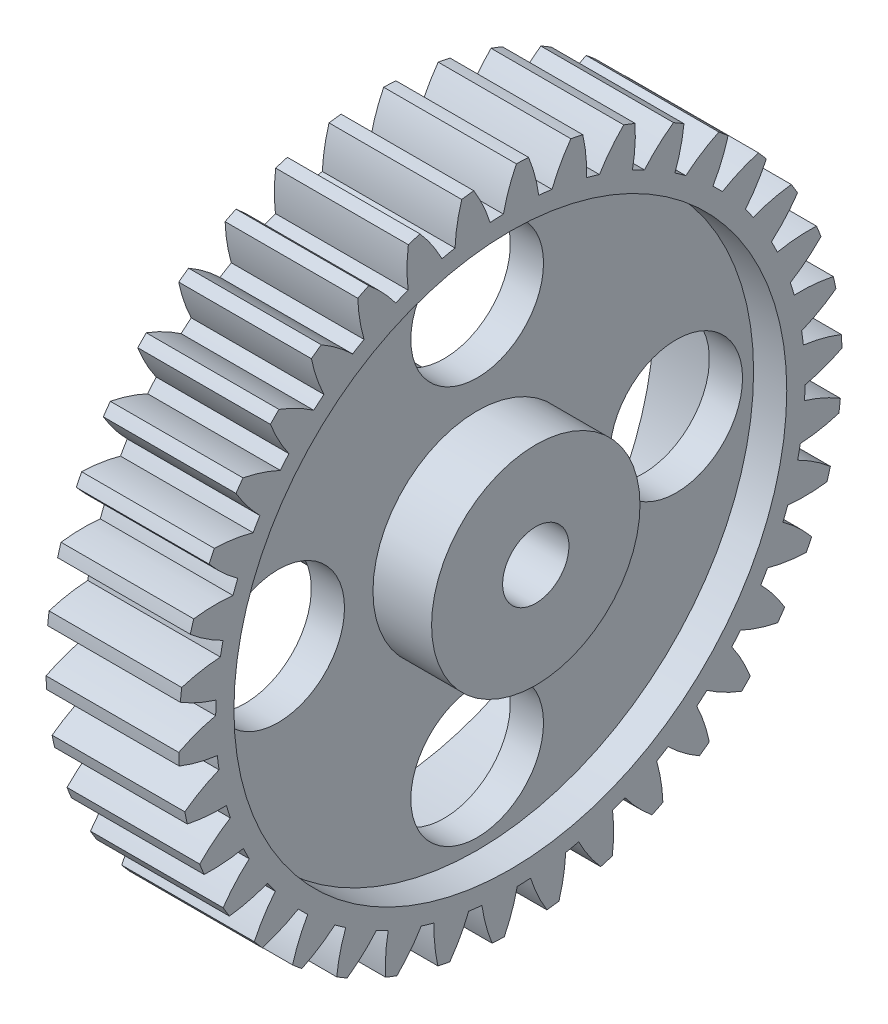
from build123d import *

# Parameters (mm, degrees)
SKETCH1_R                = 6
SKETCH1_R_2              = 3
BOSS_EXTRUDE1_DEPTH      = 12
BOSS_EXTRUDE2_DEPTH      = 2.3
BOSS_EXTRUDE2_DEPTH_BACK = 3
SKETCH2_R                = 9.425
SKETCH2_R_2              = 3
BOSS_EXTRUDE3_DEPTH      = 8.3
BOSS_EXTRUDE3_DEPTH_BACK = 6
SKETCH3_R                = 7.325
SKETCH3_R_2              = 3
CUT_EXTRUDE1_START       = -3
SKETCH4_R                = 25
SKETCH4_R_2              = 9.425
CUT_EXTRUDE1_DEPTH       = 3
SKETCH5_R                = 25
SKETCH5_R_2              = 7.325
CUT_EXTRUDE2_DEPTH       = 6


with BuildPart() as part:
    # Sketch1 → Boss-Extrude1 (new body)
    with BuildSketch(Plane(origin=(0, 0, 0), x_dir=(0, 0, -1), z_dir=(1, 0, 0))):
        with BuildLine():
            ThreePointArc((0.545834956, 29.995033992), (-0.144682898, 28.355188049), (-0.62738395, 26.642614162))
            ThreePointArc((-0.62738395, 26.642614162), (-1.229291333, 26.621632986), (-1.830570879, 26.587055314))
            ThreePointArc((-1.830570879, 26.587055314), (-2.469042312, 28.247857485), (-3.307743856, 29.817089573))
            ThreePointArc((-3.307743856, 29.817089573), (-3.853834567, 29.751436253), (-4.398629852, 29.675782305))
            ThreePointArc((-4.398629852, 29.675782305), (-4.809820172, 27.94464622), (-5.004057412, 26.175979627))
            ThreePointArc((-5.004057412, 26.175979627), (-5.594302175, 26.056213907), (-6.181689754, 25.923140469))
            ThreePointArc((-6.181689754, 25.923140469), (-7.084812322, 27.45620252), (-8.170362183, 28.86598659))
            ThreePointArc((-8.170362183, 28.86598659), (-8.698198747, 28.711345119), (-9.223111504, 28.547052636))
            ThreePointArc((-9.223111504, 28.547052636), (-9.343758089, 26.771847288), (-9.244233233, 24.995332603))
            ThreePointArc((-9.244233233, 24.995332603), (-9.806715037, 24.780049237), (-10.364188247, 24.552109929))
            ThreePointArc((-10.364188247, 24.552109929), (-11.507327121, 25.915613923), (-12.810114328, 27.127494741))
            ThreePointArc((-12.810114328, 27.127494741), (-13.305298739, 26.888083335), (-13.796010717, 26.639633787))
            ThreePointArc((-13.796010717, 26.639633787), (-13.622822643, 24.868782151), (-13.23225047, 23.132878064))
            ThreePointArc((-13.23225047, 23.132878064), (-13.751626278, 22.82794942), (-14.263978703, 22.511361833))
            ThreePointArc((-14.263978703, 22.511361833), (-15.615952033, 23.668114934), (-17.100439947, 24.649035551))
            ThreePointArc((-17.100439947, 24.649035551), (-17.549464867, 24.33138473), (-17.992590721, 24.005555173))
            ThreePointArc((-17.992590721, 24.005555173), (-17.530292107, 22.287361466), (-16.859326407, 20.639418914))
            ThreePointArc((-16.859326407, 20.639418914), (-17.321429001, 20.253162651), (-17.774685002, 19.856562469))
            ThreePointArc((-17.774685002, 19.856562469), (-19.298614482, 20.775011469), (-20.924310142, 21.498214927))
            ThreePointArc((-20.924310142, 21.498214927), (-21.314927341, 21.110989377), (-21.698379753, 20.716667591))
            ThreePointArc((-21.698379753, 20.716667591), (-20.9595809, 19.097999658), (-20.026523869, 17.582970219))
            ThreePointArc((-20.026523869, 17.582970219), (-20.418748294, 17.125922401), (-20.80054423, 16.660127842))
            ThreePointArc((-20.80054423, 16.660127842), (-22.454861035, 17.315219847), (-24.177419703, 17.760979042))
            ThreePointArc((-24.177419703, 17.760979042), (-24.498974161, 17.314741265), (-24.812293549, 16.862683322))
            ThreePointArc((-24.812293549, 16.862683322), (-23.817146964, 15.387694204), (-22.647449965, 14.046903932))
            ThreePointArc((-22.647449965, 14.046903932), (-22.959097362, 13.531531632), (-23.259018835, 13.009248358))
            ThreePointArc((-23.259018835, 13.009248358), (-24.998597514, 13.383114165), (-26.771032279, 13.539269947))
            ThreePointArc((-26.771032279, 13.539269947), (-27.014752829, 13.046192148), (-27.249392658, 12.54872901))
            ThreePointArc((-27.249392658, 12.54872901), (-26.025043346, 11.257652565), (-24.650612664, 10.127674723))
            ThreePointArc((-24.650612664, 10.127674723), (-24.873182104, 9.568035954), (-25.083048037, 9.003510491))
            ThreePointArc((-25.083048037, 9.003510491), (-26.86043742, 9.085952016), (-28.634400882, 8.948244863))
            ThreePointArc((-28.634400882, 8.948244863), (-28.793639463, 8.421776918), (-28.943199369, 7.892478083))
            ThreePointArc((-28.943199369, 7.892478083), (-27.523044387, 6.820531511), (-25.981370908, 5.932188949))
            ThreePointArc((-25.981370908, 5.932188949), (-26.108791278, 5.343549197), (-26.222877076, 4.752180329))
            ThreePointArc((-26.222877076, 4.752180329), (-27.989594613, 4.540948782), (-29.716697673, 4.113134985))
            ThreePointArc((-29.716697673, 4.113134985), (-29.787110672, 3.567637568), (-29.847511051, 3.020940927))
            ThreePointArc((-29.847511051, 3.020940927), (-28.270288525, 2.197364137), (-26.603425083, 1.574888524))
            ThreePointArc((-26.603425083, 1.574888524), (-26.632220686, 0.973304348), (-26.647414385, 0.371223075))
            ThreePointArc((-26.647414385, 0.371223075), (-28.355268629, -0.127919699), (-29.988400417, -0.834170493))
            ThreePointArc((-29.988400417, -0.834170493), (-29.968067151, -1.383817635), (-29.937660437, -1.932999622))
            ThreePointArc((-29.937660437, -1.932999622), (-28.246392887, -2.485741603), (-26.499807171, -2.825370754))
            ThreePointArc((-26.499807171, -2.825370754), (-26.429192538, -3.423489707), (-26.345079695, -4.019860177))
            ThreePointArc((-26.345079695, -4.019860177), (-27.947484832, -4.793298863), (-29.442097772, -5.758721975))
            ThreePointArc((-29.442097772, -5.758721975), (-29.331572879, -6.297525901), (-29.211188489, -6.83421298))
            ThreePointArc((-29.211188489, -6.83421298), (-27.452009284, -7.101042791), (-25.673343599, -7.148561284))
            ThreePointArc((-25.673343599, -7.148561284), (-25.505244914, -7.726899887), (-25.324119908, -8.301292122))
            ThreePointArc((-25.324119908, -8.301292122), (-26.777366504, -9.327929329), (-28.092691449, -10.526190533))
            ThreePointArc((-28.092691449, -10.526190533), (-27.89498976, -11.039454076), (-27.687911467, -11.549006824))
            ThreePointArc((-27.687911467, -11.549006824), (-25.908806429, -11.522646044), (-24.14657814, -11.276757696))
            ThreePointArc((-24.14657814, -11.276757696), (-23.885580696, -11.81954038), (-23.612384144, -12.356286458))
            ThreePointArc((-23.612384144, -12.356286458), (-24.87683142, -13.6081182), (-25.976989736, -15.006532053))
            ThreePointArc((-25.976989736, -15.006532053), (-25.697504038, -15.480254721), (-25.409380396, -15.948773867))
            ThreePointArc((-25.409380396, -15.948773867), (-23.658878875, -15.629941549), (-21.961156974, -15.097353555))
            ThreePointArc((-21.961156974, -15.097353555), (-21.614380102, -15.589774623), (-21.256564094, -16.074233509))
            ThreePointArc((-21.256564094, -16.074233509), (-22.297721225, -17.517113079), (-23.15270346, -19.077534497))
            ThreePointArc((-23.15270346, -19.077534497), (-22.799057393, -19.498794372), (-22.437747666, -19.913499935))
            ThreePointArc((-22.437747666, -19.913499935), (-20.763598779, -19.310892994), (-19.176692694, -18.506132965))
            ThreePointArc((-19.176692694, -18.506132965), (-18.753595563, -18.934760454), (-18.320920387, -19.353717373))
            ThreePointArc((-18.320920387, -19.353717373), (-19.11038732, -20.948286778), (-19.696871788, -22.628151532))
            ThreePointArc((-19.696871788, -22.628151532), (-19.278711896, -22.985457742), (-18.854071671, -23.335037635))
            ThreePointArc((-18.854071671, -23.335037635), (-17.301941834, -22.465093617), (-15.869138228, -21.410113309))
            ThreePointArc((-15.869138228, -21.410113309), (-15.381261824, -21.763255379), (-14.885529731, -22.105282279))
            ThreePointArc((-14.885529731, -22.105282279), (-15.401771866, -23.808045821), (-15.703760799, -25.561531581))
            ThreePointArc((-15.703760799, -25.561531581), (-15.232493394, -25.845137744), (-14.756105749, -26.120056339))
            ThreePointArc((-14.756105749, -26.120056339), (-13.36833302, -25.006505048), (-12.128715038, -23.730081574))
            ThreePointArc((-12.128715038, -23.730081574), (-11.589367358, -23.99810543), (-11.044100628, -24.253872708))
            ThreePointArc((-11.044100628, -24.253872708), (-11.273036225, -26.018383438), (-11.282292153, -27.797659682))
            ThreePointArc((-11.282292153, -27.797659682), (-10.770772181, -27.999829761), (-10.255631728, -28.192587995))
            ThreePointArc((-10.255631728, -28.192587995), (-9.070070929, -26.865804209), (-8.05745212, -25.402755074))
            ThreePointArc((-8.05745212, -25.402755074), (-7.481345162, -25.578349723), (-6.901417249, -25.740880714))
            ThreePointArc((-6.901417249, -25.740880714), (-6.836801542, -27.519007379), (-6.553071987, -29.275540089))
            ThreePointArc((-6.553071987, -29.275540089), (-6.01525238, -29.390759412), (-5.475410809, -29.496099343))
            ThreePointArc((-5.475410809, -29.496099343), (-4.524400947, -27.992274265), (-3.766402912, -26.382507635))
            ThreePointArc((-3.766402912, -26.382507635), (-3.169251373, -26.460883314), (-2.570481198, -26.525744597))
            ThreePointArc((-2.570481198, -26.525744597), (-2.214076736, -28.268984535), (-1.6451011, -29.954860079))
            ThreePointArc((-1.6451011, -29.954860079), (-1.095652174, -29.979985762), (-0.545834956, -29.995033992))
            ThreePointArc((-0.545834956, -29.995033992), (0.144682898, -28.355188049), (0.62738395, -26.642614162))
            ThreePointArc((0.62738395, -26.642614162), (1.229291333, -26.621632986), (1.830570879, -26.587055314))
            ThreePointArc((1.830570879, -26.587055314), (2.469042312, -28.247857485), (3.307743856, -29.817089573))
            ThreePointArc((3.307743856, -29.817089573), (3.853834567, -29.751436253), (4.398629852, -29.675782305))
            ThreePointArc((4.398629852, -29.675782305), (4.809820172, -27.94464622), (5.004057412, -26.175979627))
            ThreePointArc((5.004057412, -26.175979627), (5.594302175, -26.056213907), (6.181689754, -25.923140469))
            ThreePointArc((6.181689754, -25.923140469), (7.084812322, -27.45620252), (8.170362183, -28.86598659))
            ThreePointArc((8.170362183, -28.86598659), (8.698198747, -28.711345119), (9.223111504, -28.547052636))
            ThreePointArc((9.223111504, -28.547052636), (9.343758089, -26.771847288), (9.244233233, -24.995332603))
            ThreePointArc((9.244233233, -24.995332603), (9.806715037, -24.780049237), (10.364188247, -24.552109929))
            ThreePointArc((10.364188247, -24.552109929), (11.507327121, -25.915613923), (12.810114328, -27.127494741))
            ThreePointArc((12.810114328, -27.127494741), (13.305298739, -26.888083335), (13.796010717, -26.639633787))
            ThreePointArc((13.796010717, -26.639633787), (13.622822643, -24.868782151), (13.23225047, -23.132878064))
            ThreePointArc((13.23225047, -23.132878064), (13.751626278, -22.82794942), (14.263978703, -22.511361833))
            ThreePointArc((14.263978703, -22.511361833), (15.615952033, -23.668114934), (17.100439947, -24.649035551))
            ThreePointArc((17.100439947, -24.649035551), (17.549464867, -24.33138473), (17.992590721, -24.005555173))
            ThreePointArc((17.992590721, -24.005555173), (17.530292107, -22.287361466), (16.859326407, -20.639418914))
            ThreePointArc((16.859326407, -20.639418914), (17.321429001, -20.253162651), (17.774685002, -19.856562469))
            ThreePointArc((17.774685002, -19.856562469), (19.298614482, -20.775011469), (20.924310142, -21.498214927))
            ThreePointArc((20.924310142, -21.498214927), (21.314927341, -21.110989377), (21.698379753, -20.716667591))
            ThreePointArc((21.698379753, -20.716667591), (20.9595809, -19.097999658), (20.026523869, -17.582970219))
            ThreePointArc((20.026523869, -17.582970219), (20.418748294, -17.125922401), (20.80054423, -16.660127842))
            ThreePointArc((20.80054423, -16.660127842), (22.454861035, -17.315219847), (24.177419703, -17.760979042))
            ThreePointArc((24.177419703, -17.760979042), (24.498974161, -17.314741265), (24.812293549, -16.862683322))
            ThreePointArc((24.812293549, -16.862683322), (23.817146964, -15.387694204), (22.647449965, -14.046903932))
            ThreePointArc((22.647449965, -14.046903932), (22.959097362, -13.531531632), (23.259018835, -13.009248358))
            ThreePointArc((23.259018835, -13.009248358), (24.998597514, -13.383114165), (26.771032279, -13.539269947))
            ThreePointArc((26.771032279, -13.539269947), (27.014752829, -13.046192148), (27.249392658, -12.54872901))
            ThreePointArc((27.249392658, -12.54872901), (26.025043346, -11.257652565), (24.650612664, -10.127674723))
            ThreePointArc((24.650612664, -10.127674723), (24.873182104, -9.568035954), (25.083048037, -9.003510491))
            ThreePointArc((25.083048037, -9.003510491), (26.86043742, -9.085952016), (28.634400882, -8.948244863))
            ThreePointArc((28.634400882, -8.948244863), (28.793639463, -8.421776918), (28.943199369, -7.892478083))
            ThreePointArc((28.943199369, -7.892478083), (27.523044387, -6.820531511), (25.981370908, -5.932188949))
            ThreePointArc((25.981370908, -5.932188949), (26.108791278, -5.343549197), (26.222877076, -4.752180329))
            ThreePointArc((26.222877076, -4.752180329), (27.989594613, -4.540948782), (29.716697673, -4.113134985))
            ThreePointArc((29.716697673, -4.113134985), (29.787110672, -3.567637568), (29.847511051, -3.020940927))
            ThreePointArc((29.847511051, -3.020940927), (28.270288525, -2.197364137), (26.603425083, -1.574888524))
            ThreePointArc((26.603425083, -1.574888524), (26.632220686, -0.973304348), (26.647414385, -0.371223075))
            ThreePointArc((26.647414385, -0.371223075), (28.355268629, 0.127919699), (29.988400417, 0.834170493))
            ThreePointArc((29.988400417, 0.834170493), (29.968067151, 1.383817635), (29.937660437, 1.932999622))
            ThreePointArc((29.937660437, 1.932999622), (28.246392887, 2.485741603), (26.499807171, 2.825370754))
            ThreePointArc((26.499807171, 2.825370754), (26.429192538, 3.423489707), (26.345079695, 4.019860177))
            ThreePointArc((26.345079695, 4.019860177), (27.947484832, 4.793298863), (29.442097772, 5.758721975))
            ThreePointArc((29.442097772, 5.758721975), (29.331572879, 6.297525901), (29.211188489, 6.83421298))
            ThreePointArc((29.211188489, 6.83421298), (27.452009284, 7.101042791), (25.673343599, 7.148561284))
            ThreePointArc((25.673343599, 7.148561284), (25.505244914, 7.726899887), (25.324119908, 8.301292122))
            ThreePointArc((25.324119908, 8.301292122), (26.777366504, 9.327929329), (28.092691449, 10.526190533))
            ThreePointArc((28.092691449, 10.526190533), (27.89498976, 11.039454076), (27.687911467, 11.549006824))
            ThreePointArc((27.687911467, 11.549006824), (25.908806429, 11.522646044), (24.14657814, 11.276757696))
            ThreePointArc((24.14657814, 11.276757696), (23.885580696, 11.81954038), (23.612384144, 12.356286458))
            ThreePointArc((23.612384144, 12.356286458), (24.87683142, 13.6081182), (25.976989736, 15.006532053))
            ThreePointArc((25.976989736, 15.006532053), (25.697504038, 15.480254721), (25.409380396, 15.948773867))
            ThreePointArc((25.409380396, 15.948773867), (23.658878875, 15.629941549), (21.961156974, 15.097353555))
            ThreePointArc((21.961156974, 15.097353555), (21.614380102, 15.589774623), (21.256564094, 16.074233509))
            ThreePointArc((21.256564094, 16.074233509), (22.297721225, 17.517113079), (23.15270346, 19.077534497))
            ThreePointArc((23.15270346, 19.077534497), (22.799057393, 19.498794372), (22.437747666, 19.913499935))
            ThreePointArc((22.437747666, 19.913499935), (20.763598779, 19.310892994), (19.176692694, 18.506132965))
            ThreePointArc((19.176692694, 18.506132965), (18.753595563, 18.934760454), (18.320920387, 19.353717373))
            ThreePointArc((18.320920387, 19.353717373), (19.11038732, 20.948286778), (19.696871788, 22.628151532))
            ThreePointArc((19.696871788, 22.628151532), (19.278711896, 22.985457742), (18.854071671, 23.335037635))
            ThreePointArc((18.854071671, 23.335037635), (17.301941834, 22.465093617), (15.869138228, 21.410113309))
            ThreePointArc((15.869138228, 21.410113309), (15.381261824, 21.763255379), (14.885529731, 22.105282279))
            ThreePointArc((14.885529731, 22.105282279), (15.401771866, 23.808045821), (15.703760799, 25.561531581))
            ThreePointArc((15.703760799, 25.561531581), (15.232493394, 25.845137744), (14.756105749, 26.120056339))
            ThreePointArc((14.756105749, 26.120056339), (13.36833302, 25.006505048), (12.128715038, 23.730081574))
            ThreePointArc((12.128715038, 23.730081574), (11.589367358, 23.99810543), (11.044100628, 24.253872708))
            ThreePointArc((11.044100628, 24.253872708), (11.273036225, 26.018383438), (11.282292153, 27.797659682))
            ThreePointArc((11.282292153, 27.797659682), (10.770772181, 27.999829761), (10.255631728, 28.192587995))
            ThreePointArc((10.255631728, 28.192587995), (9.070070929, 26.865804209), (8.05745212, 25.402755074))
            ThreePointArc((8.05745212, 25.402755074), (7.481345162, 25.578349723), (6.901417249, 25.740880714))
            ThreePointArc((6.901417249, 25.740880714), (6.836801542, 27.519007379), (6.553071987, 29.275540089))
            ThreePointArc((6.553071987, 29.275540089), (6.01525238, 29.390759412), (5.475410809, 29.496099343))
            ThreePointArc((5.475410809, 29.496099343), (4.524400947, 27.992274265), (3.766402912, 26.382507635))
            ThreePointArc((3.766402912, 26.382507635), (3.169251373, 26.460883314), (2.570481198, 26.525744597))
            ThreePointArc((2.570481198, 26.525744597), (2.214076736, 28.268984535), (1.6451011, 29.954860079))
            ThreePointArc((1.6451011, 29.954860079), (1.095652174, 29.979985762), (0.545834956, 29.995033992))
        make_face()
        with Locations((18, 0)):
            Circle(SKETCH1_R, mode=Mode.SUBTRACT)
        with Locations((-18, 0)):
            Circle(SKETCH1_R, mode=Mode.SUBTRACT)
        with Locations((0, -18)):
            Circle(SKETCH1_R, mode=Mode.SUBTRACT)
        Circle(SKETCH1_R_2, mode=Mode.SUBTRACT)
        with Locations((0, 18)):
            Circle(SKETCH1_R, mode=Mode.SUBTRACT)
    extrude(amount=BOSS_EXTRUDE1_DEPTH)

    # Sketch2 → Boss-Extrude2 (add, two sides: drawn at the far end of the back side and taken through both)
    with BuildSketch(Plane(origin=(12, 0, 0), x_dir=(0, 0, -1), z_dir=(1, 0, 0)).offset(-BOSS_EXTRUDE2_DEPTH_BACK)):
        Circle(SKETCH2_R)
        Circle(SKETCH2_R_2, mode=Mode.SUBTRACT)
    extrude(amount=BOSS_EXTRUDE2_DEPTH + BOSS_EXTRUDE2_DEPTH_BACK)

    # Sketch3 → Boss-Extrude3 (add, two sides: drawn at the far end of the back side and taken through both)
    with BuildSketch(Plane.ZY.offset(-BOSS_EXTRUDE3_DEPTH_BACK)):
        Circle(SKETCH3_R)
        Circle(SKETCH3_R_2, mode=Mode.SUBTRACT)
    extrude(amount=BOSS_EXTRUDE3_DEPTH + BOSS_EXTRUDE3_DEPTH_BACK)

    # Sketch4 → Cut-Extrude1 (cut)
    with BuildSketch(Plane(origin=(12, 0, 0), x_dir=(0, 0, -1), z_dir=(1, 0, 0)).offset(CUT_EXTRUDE1_START)):
        Circle(SKETCH4_R)
        Circle(SKETCH4_R_2, mode=Mode.SUBTRACT)
    extrude(amount=CUT_EXTRUDE1_DEPTH, mode=Mode.SUBTRACT)

    # Sketch5 → Cut-Extrude2 (cut)
    with BuildSketch(Plane.ZY):
        with Locations(Location((0, 0, 0), (0, 0, 180))):
            Circle(SKETCH5_R)
        Circle(SKETCH5_R_2, mode=Mode.SUBTRACT)
    extrude(amount=-CUT_EXTRUDE2_DEPTH, mode=Mode.SUBTRACT)


solid = part.part
